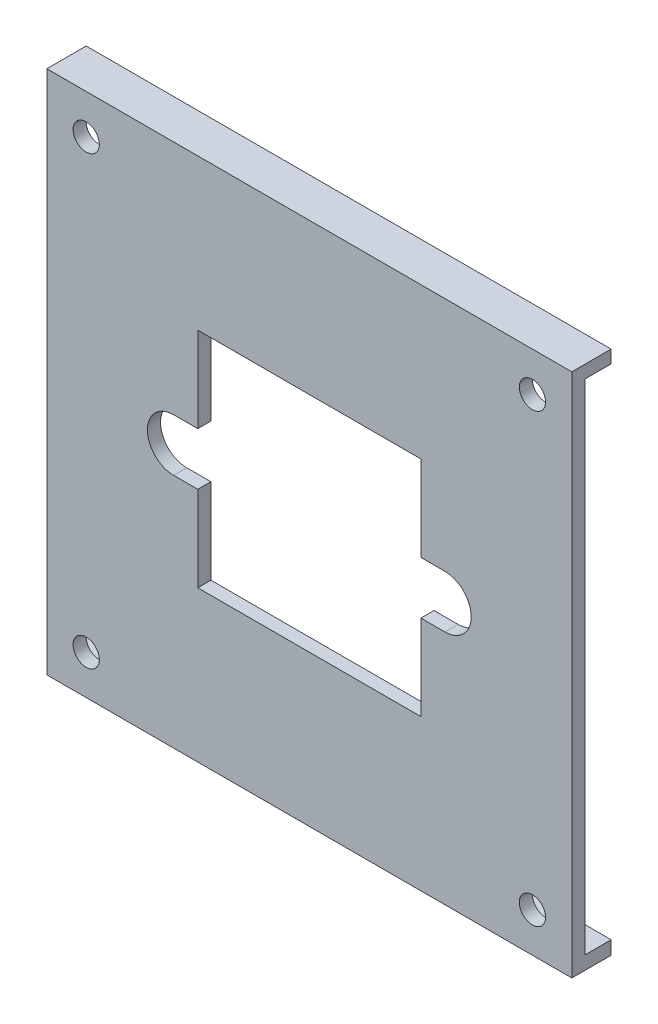
from build123d import *

# Parameters (mm, degrees)
SKETCH1_W           = 40
SKETCH1_H           = 40
BOSS_EXTRUDE1_DEPTH = 3
SKETCH2_R           = 1
CUT_EXTRUDE1_DEPTH  = 10
SKETCH3_W           = 17
SKETCH3_H           = 17
CUT_EXTRUDE3_DEPTH  = 10
SKETCH4_W           = 2
SKETCH4_H           = 38
CUT_EXTRUDE4_DEPTH  = 41
CUT_EXTRUDE5_DEPTH  = 4


with BuildPart() as part:
    # Sketch1 → Boss-Extrude1 (new body)
    with BuildSketch(Plane.XY):
        with Locations((20, 20)):
            Rectangle(SKETCH1_W, SKETCH1_H)
    extrude(amount=BOSS_EXTRUDE1_DEPTH)

    # Sketch2 → Cut-Extrude1 (cut)
    with BuildSketch(Plane.XY.offset(3)):
        with Locations((3, 37)):
            Circle(SKETCH2_R)
        with Locations((3, 3)):
            Circle(SKETCH2_R)
        with Locations((37, 37)):
            Circle(SKETCH2_R)
        with Locations((37, 3)):
            Circle(SKETCH2_R)
    extrude(amount=-CUT_EXTRUDE1_DEPTH, mode=Mode.SUBTRACT)

    # Sketch3 → Cut-Extrude3 (cut)
    with BuildSketch(Plane(origin=(0, 0, 0), x_dir=(-1, 0, 0), z_dir=(0, 0, -1))):
        with Locations((-20, 20)):
            Rectangle(SKETCH3_W, SKETCH3_H)
    extrude(amount=-CUT_EXTRUDE3_DEPTH, mode=Mode.SUBTRACT)

    # Sketch4 → Cut-Extrude4 (cut, through all)
    with BuildSketch(Plane(origin=(40, 0, 0), x_dir=(0, 0, -1), z_dir=(1, 0, 0))):
        with Locations((-1, 20.024894978)):
            Rectangle(SKETCH4_W, SKETCH4_H)
    extrude(amount=-CUT_EXTRUDE4_DEPTH, mode=Mode.SUBTRACT)

    # Sketch7 → Cut-Extrude5 (cut, through all)
    with BuildSketch(Plane.XY.offset(3)):
        with BuildLine():
            Line((11.5, 22), (9.66485435, 22))
            ThreePointArc((9.66485435, 22), (7.66485435, 20), (9.66485435, 18))
            Line((9.66485435, 18), (11.5, 18))
            Line((11.5, 18), (11.5, 22))
        make_face()
        with BuildLine():
            Line((28.5, 22), (30.33514565, 22))
            ThreePointArc((30.33514565, 22), (32.33514565, 20), (30.33514565, 18))
            Line((30.33514565, 18), (28.5, 18))
            Line((28.5, 18), (28.5, 22))
        make_face()
    extrude(amount=-CUT_EXTRUDE5_DEPTH, mode=Mode.SUBTRACT)


solid = part.part
